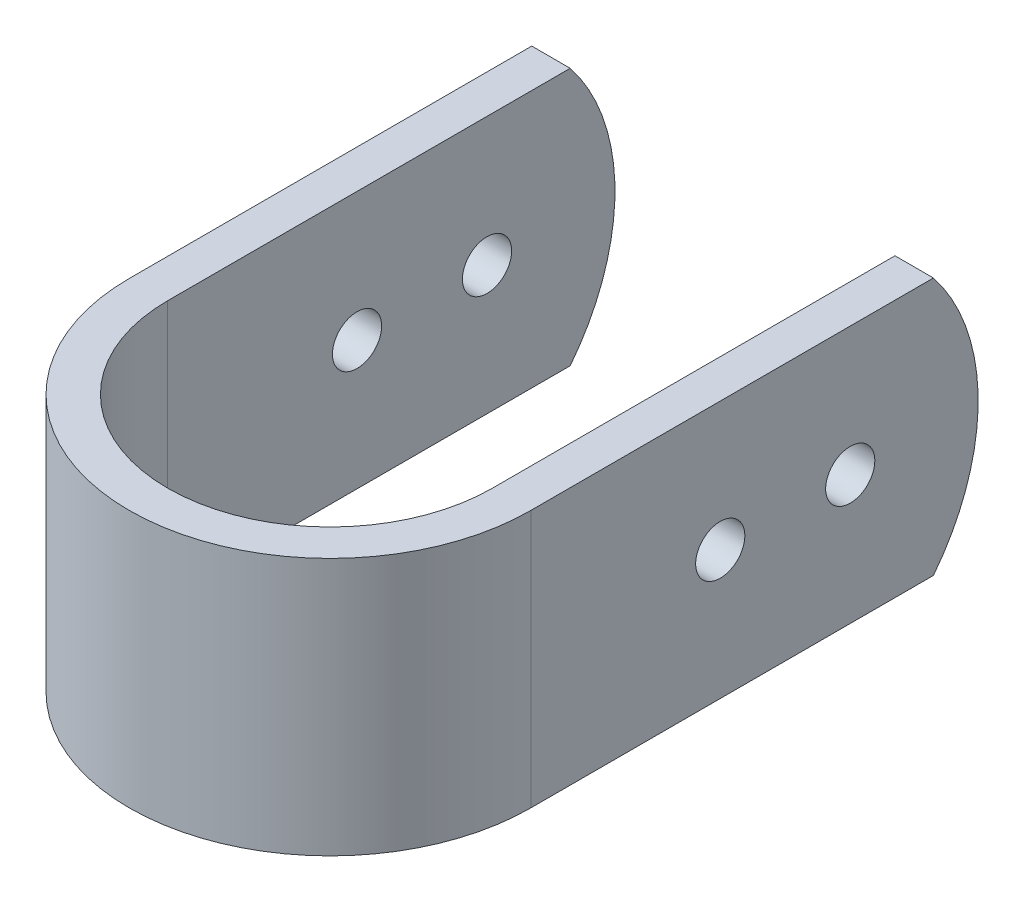
from build123d import *

# Parameters (mm, degrees)
BOSS_EXTRUDE1_DEPTH  = 28.8
M5_CLEARANCE_HOLE1_D = 5.5
CUT_EXTRUDE1_DEPTH   = 45.9


with BuildPart() as part:
    # Sketch1 → Boss-Extrude1 (new body)
    with BuildSketch(Plane(origin=(0, 0, 0), x_dir=(1, 0, 0), z_dir=(0, 1, 0))):
        with BuildLine():
            Line((-22.45, 0), (-22.45, 50))
            Line((-22.45, 50), (-18.15, 50))
            Line((-18.15, 50), (-18.15, 0))
            ThreePointArc((-18.15, 0), (0, -18.15), (18.15, 0))
            Line((18.15, 0), (18.15, 50))
            Line((18.15, 50), (22.45, 50))
            Line((22.45, 50), (22.45, 0))
            ThreePointArc((22.45, 0), (0, -22.45), (-22.45, 0))
        make_face()
    extrude(amount=BOSS_EXTRUDE1_DEPTH)

    # M5 Clearance Hole1 (through all)
    with Locations(Plane(origin=(22.45, 0, 0), x_dir=(0, 0, -1), z_dir=(1, 0, 0))):
        with Locations((21.17, 14.4), (35.7, 14.4)):
            Hole(M5_CLEARANCE_HOLE1_D / 2)

    # Sketch5 → Cut-Extrude1 (cut, through all)
    with BuildSketch(Plane(origin=(22.45, 0, 0), x_dir=(0, 0, -1), z_dir=(1, 0, 0))):
        with BuildLine():
            Line((50, 0), (50, 14.4))
            ThreePointArc((50, 14.4), (48.714437262, 6.778320395), (45, 0))
            Line((45, 0), (50, 0))
        make_face()
        with BuildLine():
            Line((50, 28.8), (45, 28.8))
            ThreePointArc((45, 28.8), (48.714437262, 22.021679605), (50, 14.4))
            Line((50, 14.4), (50, 28.8))
        make_face()
    extrude(amount=-CUT_EXTRUDE1_DEPTH, mode=Mode.SUBTRACT)


solid = part.part
